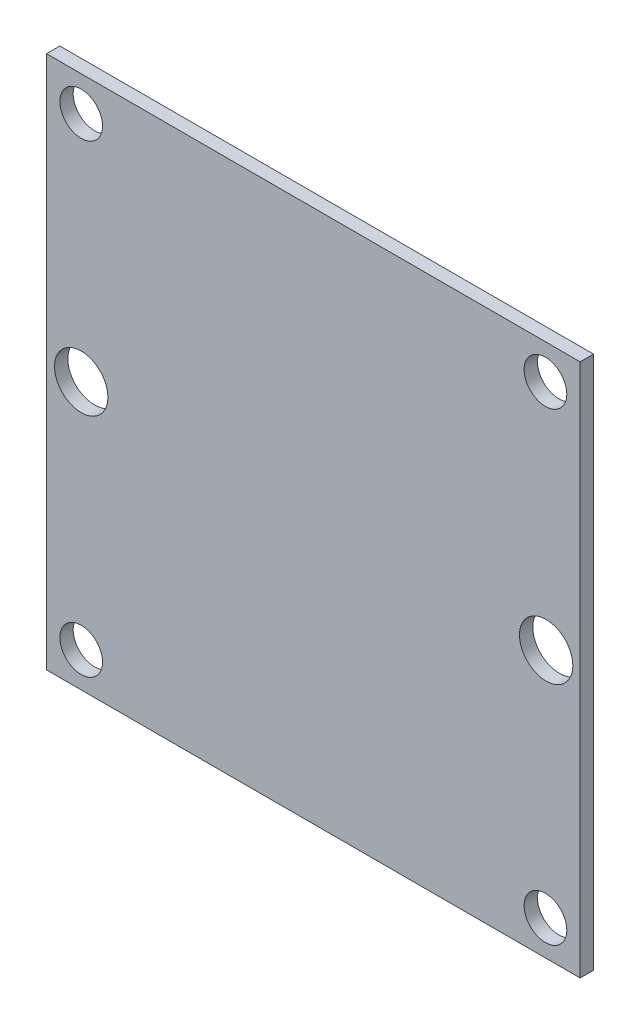
from build123d import *

# Parameters (mm, degrees)
SKETCH1_W           = 40
SKETCH1_H           = 40
BOSS_EXTRUDE1_DEPTH = 1
SKETCH2_R           = 1.6
SKETCH2_R_2         = 2
CUT_EXTRUDE1_DEPTH  = 10


with BuildPart() as part:
    # Sketch1 → Boss-Extrude1 (new body)
    with BuildSketch(Plane.XY):
        Rectangle(SKETCH1_W, SKETCH1_H)
    extrude(amount=BOSS_EXTRUDE1_DEPTH)

    # Sketch2 → Cut-Extrude1 (cut)
    with BuildSketch(Plane.XY.offset(1)):
        with Locations((-17.4, -17.4)):
            Circle(SKETCH2_R)
        with Locations((17.4, -17.4)):
            Circle(SKETCH2_R)
        with Locations((17.4, 17.4)):
            Circle(SKETCH2_R)
        with Locations((-17.4, 17.4)):
            Circle(SKETCH2_R)
        with Locations((17.450650527, 0)):
            Circle(SKETCH2_R_2)
        with Locations((-17.4, 0)):
            Circle(SKETCH2_R_2)
    extrude(amount=-CUT_EXTRUDE1_DEPTH, mode=Mode.SUBTRACT)


solid = part.part
